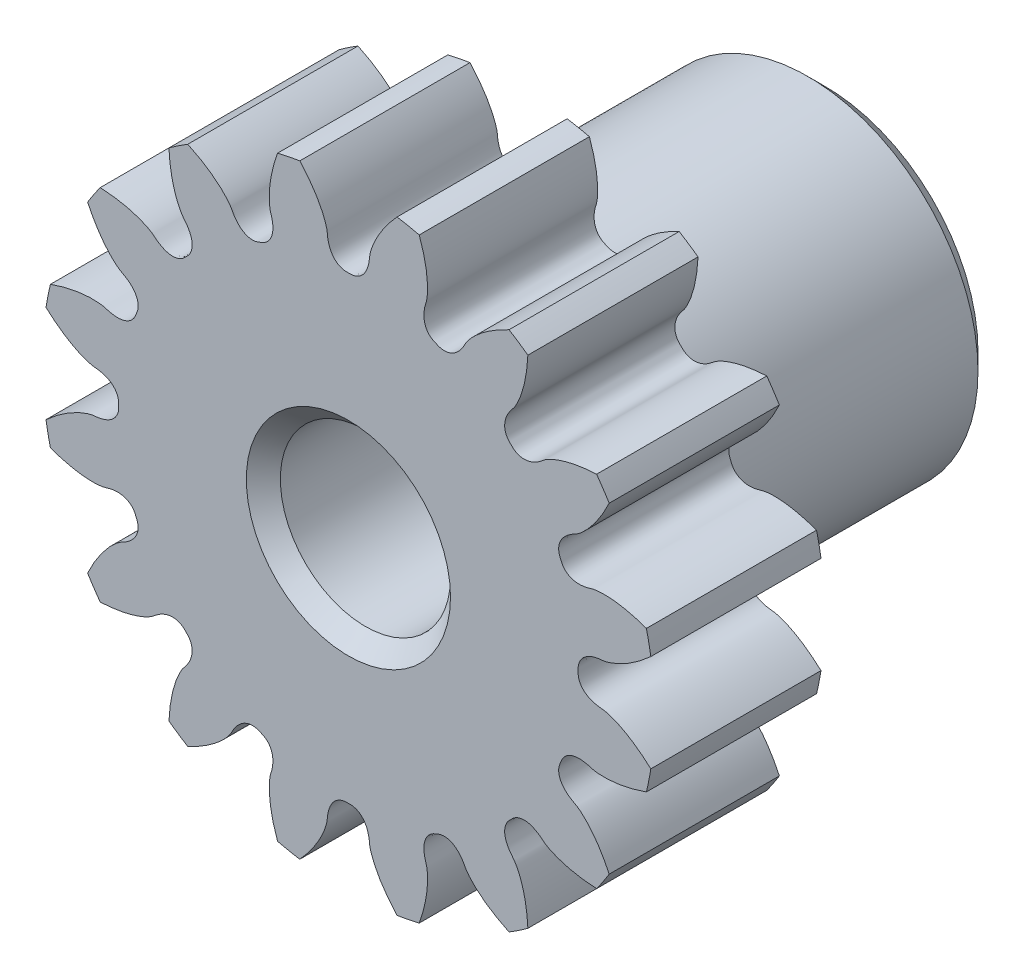
from build123d import *

# Parameters (mm, degrees)
SKETCHREVOLVESPUR01_W       = 5
SKETCHREVOLVESPUR01_H       = 8.999999865
TOOTHEXTRUDECUTSPUR01_DEPTH = 2.5
PATTERNSPUR01_COUNT         = 16


with BuildPart() as part:
    # SketchRevolveSpur01 → Spur01 (revolve)
    with BuildSketch(Plane(origin=(0, 0, 0), x_dir=(0, 0, -1), z_dir=(1, 0, 0))):
        with Locations((0, 4.499999933)):
            Rectangle(SKETCHREVOLVESPUR01_W, SKETCHREVOLVESPUR01_H)
    revolve(axis=Axis((0, 0, 0), (0, 0, -1)))

    # SketchToothSpur01 → ToothExtrudeCutSpur01 (cut, symmetric)
    with BuildSketch(Plane.XY):
        with BuildLine():
            ThreePointArc((8.929973087, 1.469039895), (9.049999864, 0), (8.929973087, -1.469039895))
            add(Edge.make_bspline(
                [(8.929973087, -1.469039895), (8.851978125, -1.395869376), (8.734664522, -1.292596236), (8.57583891, -1.166705394), (8.463809949, -1.083860011), (8.356024481, -1.009601886), (8.252924342, -0.94354839), (8.154930322, -0.885296998), (8.062441331, -0.834426521), (7.975833629, -0.790498059), (7.895460094, -0.753056095), (7.821649557, -0.721629475), (7.754706103, -0.695732826), (7.694908669, -0.674866712), (7.642509927, -0.658521816), (7.597737519, -0.646171059), (7.560788592, -0.637297087), (7.531843207, -0.631321382), (7.456606294, -0.618555844), (7.372292274, -0.61589613), (7.280187051, -0.597137902), (7.230277578, -0.585104027), (7.181723358, -0.570736422), (7.134366682, -0.553996334), (7.088060278, -0.534549671), (7.042652587, -0.511994107), (6.998026713, -0.485754394), (6.954157896, -0.455062614), (6.911217436, -0.418929585), (6.86974064, -0.376171448), (6.830837104, -0.325551158), (6.796457597, -0.266109493), (6.769211269, -0.19777182), (6.753906343, -0.126815672), (6.748689337, -0.059993138), (6.750611392, 0), (6.748689337, 0.059993138), (6.753906343, 0.126815672), (6.769211269, 0.19777182), (6.796457597, 0.266109493), (6.830837104, 0.325551158), (6.86974064, 0.376171448), (6.911217436, 0.418929585), (6.954157896, 0.455062614), (6.998026713, 0.485754394), (7.042652587, 0.511994107), (7.088060278, 0.534549671), (7.134366682, 0.553996334), (7.181723358, 0.570736422), (7.230277578, 0.585104027), (7.280187051, 0.597137902), (7.372292274, 0.61589613), (7.456606294, 0.618555844), (7.531843207, 0.631321382), (7.560788592, 0.637297087), (7.597737519, 0.646171059), (7.642509927, 0.658521816), (7.694908669, 0.674866712), (7.754706103, 0.695732826), (7.821649557, 0.721629475), (7.895460094, 0.753056095), (7.975833629, 0.790498059), (8.062441331, 0.834426521), (8.154930322, 0.885296998), (8.252924342, 0.94354839), (8.356024481, 1.009601886), (8.463809949, 1.083860011), (8.57583891, 1.166705394), (8.734664522, 1.292596236), (8.851978125, 1.395869376), (8.929973087, 1.469039895)],
                knots=[0, 0, 0, 0, 0.057702282, 0.084275702, 0.10933064, 0.132867098, 0.154885074, 0.175384569, 0.194365583, 0.211828116, 0.227772168, 0.24219774, 0.25510483, 0.266493439, 0.276363567, 0.284715214, 0.29154838, 0.296863065, 0.300659271, 0.33271427, 0.342111309, 0.351328455, 0.360411821, 0.369418049, 0.378416872, 0.387494032, 0.396754261, 0.406323461, 0.416348252, 0.426989405, 0.438403692, 0.450708125, 0.463925977, 0.47793037, 0.489702561, 0.5, 0.510297439, 0.52206963, 0.536074023, 0.549291875, 0.561596308, 0.573010595, 0.583651748, 0.593676539, 0.603245739, 0.612505968, 0.621583128, 0.630581951, 0.639588179, 0.648671545, 0.657888691, 0.66728573, 0.699340729, 0.703136935, 0.70845162, 0.715284786, 0.723636433, 0.733506561, 0.74489517, 0.75780226, 0.772227832, 0.788171884, 0.805634417, 0.824615431, 0.845114926, 0.867132902, 0.89066936, 0.915724298, 0.942297718, 1, 1, 1, 1], degree=3))
        make_face()
    toothextrudecutspur01 = extrude(amount=TOOTHEXTRUDECUTSPUR01_DEPTH, both=True, mode=Mode.SUBTRACT)

    # PatternSpur01: ToothExtrudeCutSpur01 ×16 about axis
    patternspur01_axis = Axis((0, 0, 55), (0, 0, -1))
    for i in range(1, PATTERNSPUR01_COUNT):
        add(toothextrudecutspur01.rotate(patternspur01_axis, i * 360 / PATTERNSPUR01_COUNT), mode=Mode.SUBTRACT)

    # HubSketchSide1 → HubRevolve1 (revolve)
    with BuildSketch(Plane(origin=(0, 0, 0), x_dir=(0, 0, -1), z_dir=(1, 0, 0))):
        with BuildLine():
            Line((3, 5), (11, 5))
            Line((11, 5), (11.5, 4.5))
            Line((11.5, 4.5), (11.5, 0))
            Line((11.5, 0), (2.5, 0))
            Line((2.5, 0), (2.5, 5.5))
            ThreePointArc((2.5, 5.5), (2.646446609, 5.146446609), (3, 5))
        make_face()
    revolve(axis=Axis((0, 0, 0), (0, 0, -1)))

    # BoreRevolveSketch → BoreRevolveCut (revolve, cut)
    with BuildSketch(Plane(origin=(0, 0, 0), x_dir=(0, 0, -1), z_dir=(1, 0, 0))):
        Polygon((-2.5, 0), (11.5, 0), (11.5, 3), (11, 2.5), (-2, 2.5), (-2.5, 3), align=None)
    revolve(axis=Axis((0, 0, 0), (0, 0, -1)), mode=Mode.SUBTRACT)


solid = part.part
